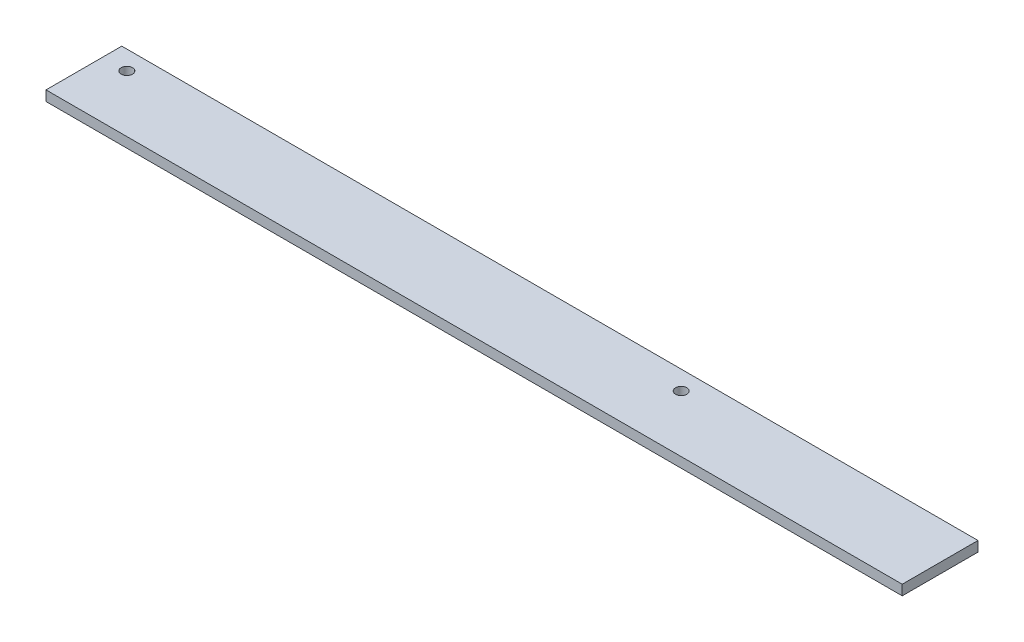
from build123d import *

# Parameters (mm, degrees)
SKETCH_1_W          = 30
SKETCH_1_H          = 4
EXTRUDE_1_DEPTH     = 339
SKETCH_2_R          = 2.25
CUT_EXTRUDE_1_DEPTH = 5


with BuildPart() as part:
    # Эскиз1 → Бобышка-Вытянуть1 (new body)
    with BuildSketch(Plane(origin=(0, 0, 0), x_dir=(0, 0, -1), z_dir=(1, 0, 0))):
        Rectangle(SKETCH_1_W, SKETCH_1_H)
    extrude(amount=EXTRUDE_1_DEPTH)

    # Эскиз2 → Вырез-Вытянуть1 (cut, through all)
    with BuildSketch(Plane(origin=(0, 2, 0), x_dir=(1, 0, 0), z_dir=(0, 1, 0))):
        with Locations((9.5, 7.5)):
            Circle(SKETCH_2_R)
        with Locations((229, 7.5)):
            Circle(SKETCH_2_R)
    extrude(amount=-CUT_EXTRUDE_1_DEPTH, mode=Mode.SUBTRACT)


solid = part.part
